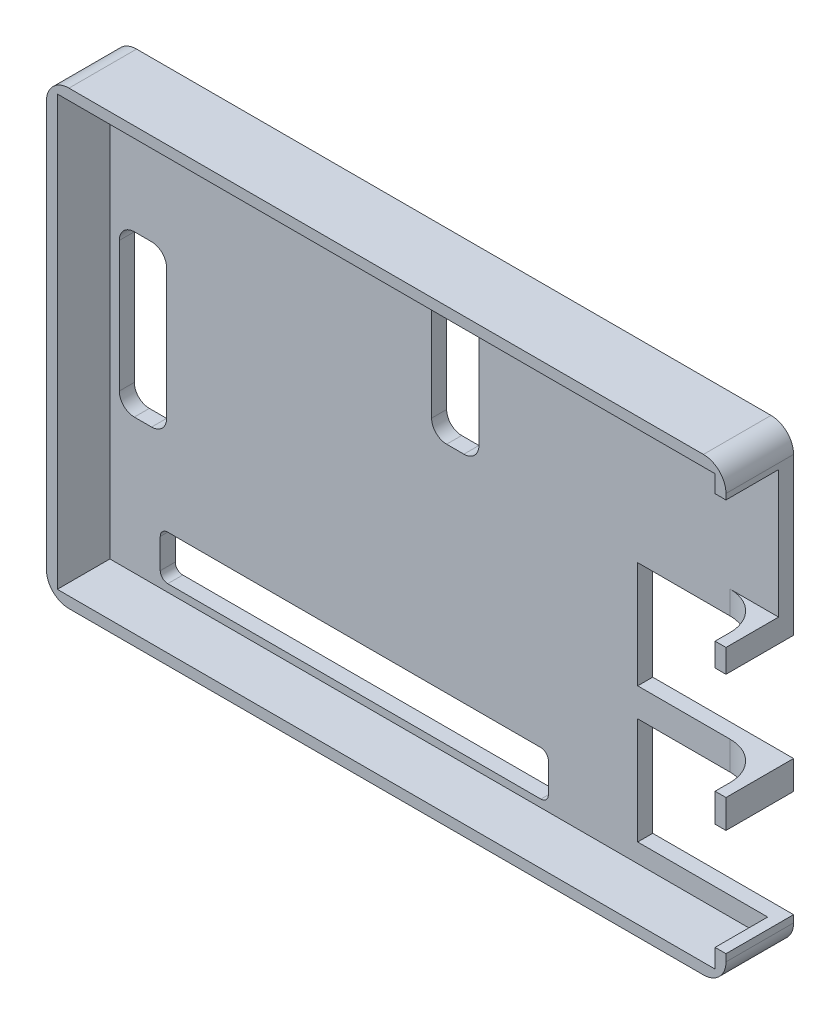
from build123d import *

# Parameters (mm, degrees)
CROQUIS1_W              = 90.45
CROQUIS1_H              = 60
SALIENTE_EXTRUIR1_DEPTH = 2
CROQUIS2_W              = 90.45
CROQUIS2_H              = 60
CROQUIS2_W_2            = 87.55
CROQUIS2_H_2            = 57.1
SALIENTE_EXTRUIR2_DEPTH = 7
CROQUIS3_W              = 18.75
CROQUIS3_H              = 14.2
CORTAR_EXTRUIR1_DEPTH   = 9
CORTAR_EXTRUIR2_REACH   = 92.45
CROQUIS4_W              = 7
CROQUIS4_H              = 17
REDONDEO2_R             = 3
CROQUIS5_W              = 51.66
CROQUIS5_H              = 5.94
CORTAR_EXTRUIR3_DEPTH   = 2
CROQUIS6_W              = 6.3
CROQUIS6_H              = 21.36
CORTAR_EXTRUIR4_DEPTH   = 2
REDONDEO3_R             = 2
REDONDEO4_R             = 1
REDONDEO5_R             = 5


with BuildPart() as part:
    # Croquis1 → Saliente-Extruir1 (new body)
    with BuildSketch(Plane.XY):
        Rectangle(CROQUIS1_W, CROQUIS1_H)
    extrude(amount=-SALIENTE_EXTRUIR1_DEPTH)

    # Croquis2 → Saliente-Extruir2 (add)
    with BuildSketch(Plane.XY):
        Rectangle(CROQUIS2_W, CROQUIS2_H)
        Rectangle(CROQUIS2_W_2, CROQUIS2_H_2, mode=Mode.SUBTRACT)
    extrude(amount=SALIENTE_EXTRUIR2_DEPTH)

    # Croquis3 → Cortar-Extruir1 (cut)
    with BuildSketch(Plane(origin=(0, 0, -2), x_dir=(-1, 0, 0), z_dir=(0, 0, -1))):
        with Locations((-35.85, -18.95)):
            Rectangle(CROQUIS3_W, CROQUIS3_H)
        with Locations((-35.85, -0.95)):
            Rectangle(CROQUIS3_W, CROQUIS3_H)
    extrude(amount=-CORTAR_EXTRUIR1_DEPTH, mode=Mode.SUBTRACT)

    # Croquis4 → Cortar-Extruir2 (cut, up to next)
    with BuildSketch(Plane(origin=(45.225, 0, 0), x_dir=(0, 0, -1), z_dir=(1, 0, 0)), mode=Mode.PRIVATE) as cortar_extruir2_sk1:
        with Locations((-3.5, 17.75)):
            Rectangle(CROQUIS4_W, CROQUIS4_H)
    cortar_extruir2_tool1 = extrude(cortar_extruir2_sk1.sketch, amount=-CORTAR_EXTRUIR2_REACH, mode=Mode.PRIVATE) & part.part
    add(cortar_extruir2_tool1.solids().sort_by_distance((45.225, 17.75, 3.5))[0], mode=Mode.SUBTRACT)

    # Redondeo2
    redondeo2_edges = [part.edges().sort_by_distance(p)[0] for p in [
        (45.225, -30, 2.5),
        (-45.225, -30, 2.5),
        (-45.225, 30, 2.5),
        (45.225, 30, 2.5),
    ]]
    fillet(redondeo2_edges, radius=REDONDEO2_R)

    # Croquis5 → Cortar-Extruir3 (cut)
    with BuildSketch(Plane(origin=(0, 0, -2), x_dir=(-1, 0, 0), z_dir=(0, 0, -1))):
        with Locations((11.245, -24.58)):
            Rectangle(CROQUIS5_W, CROQUIS5_H)
    extrude(amount=-CORTAR_EXTRUIR3_DEPTH, mode=Mode.SUBTRACT)

    # Croquis6 → Cortar-Extruir4 (cut)
    with BuildSketch(Plane(origin=(0, 0, -2), x_dir=(-1, 0, 0), z_dir=(0, 0, -1))):
        with Locations((39.375, 0.11)):
            Rectangle(CROQUIS6_W, CROQUIS6_H)
        with Locations((-2.195, 17.77)):
            Rectangle(CROQUIS6_W, CROQUIS6_H)
    extrude(amount=-CORTAR_EXTRUIR4_DEPTH, mode=Mode.SUBTRACT)

    # Redondeo3
    redondeo3_edges = [part.edges().sort_by_distance(p)[0] for p in [
        (-36.225, -10.57, -1),
        (-36.225, 10.79, -1),
        (-42.525, 10.79, -1),
        (-42.525, -10.57, -1),
        (5.345, 7.09, -1),
        (5.345, 28.45, -1),
        (-0.955, 28.45, -1),
        (-0.955, 7.09, -1),
    ]]
    fillet(redondeo3_edges, radius=REDONDEO3_R)

    # Redondeo4
    redondeo4_edges = [part.edges().sort_by_distance(p)[0] for p in [
        (14.585, -27.55, -1),
        (14.585, -21.61, -1),
        (-37.075, -21.61, -1),
        (-37.075, -27.55, -1),
    ]]
    fillet(redondeo4_edges, radius=REDONDEO4_R)

    # Redondeo5
    redondeo5_edges = [part.edges().sort_by_distance(p)[0] for p in [
        (43.775, -9.95, 0),
        (43.775, 7.7, 0),
    ]]
    fillet(redondeo5_edges, radius=REDONDEO5_R)


solid = part.part
